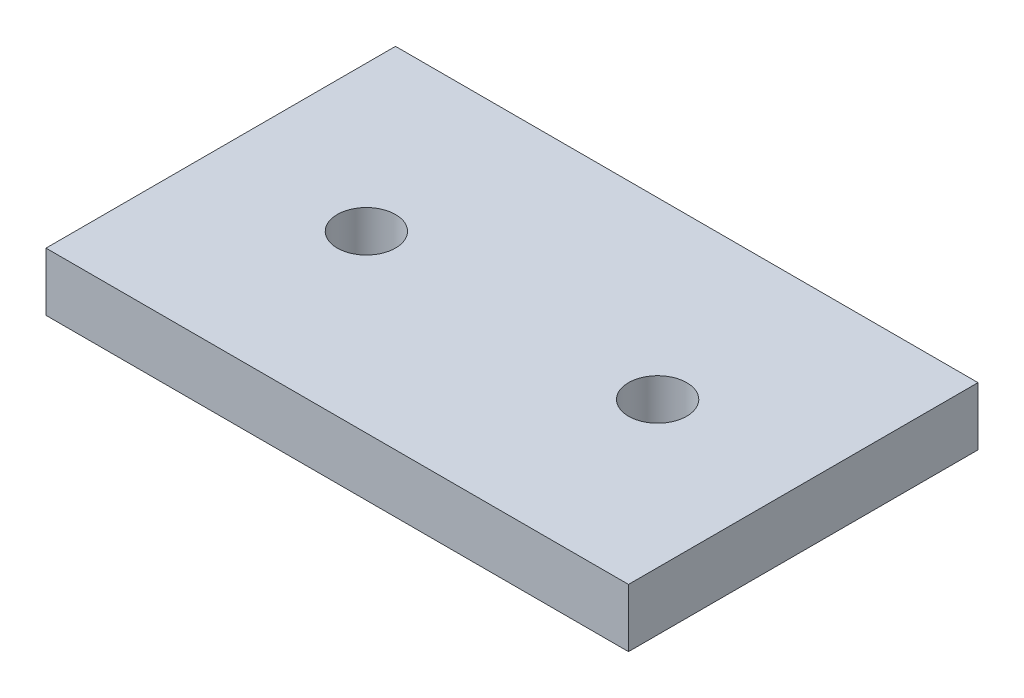
from build123d import *

# Parameters (mm, degrees)
SKETCH_1_W          = 100
SKETCH_1_H          = 60
EXTRUDE_1_DEPTH     = 10
SKETCH_2_R          = 5
CUT_EXTRUDE_1_DEPTH = 11


with BuildPart() as part:
    # Эскиз1 → Бобышка-Вытянуть1 (new body)
    with BuildSketch(Plane(origin=(0, 0, 0), x_dir=(1, 0, 0), z_dir=(0, 1, 0))):
        with Locations((50, 30)):
            Rectangle(SKETCH_1_W, SKETCH_1_H)
    extrude(amount=EXTRUDE_1_DEPTH)

    # Эскиз2 → Вырез-Вытянуть1 (cut, through all)
    with BuildSketch(Plane(origin=(0, 10, 0), x_dir=(1, 0, 0), z_dir=(0, 1, 0))):
        with Locations((25, 30)):
            Circle(SKETCH_2_R)
        with Locations((75, 30)):
            Circle(SKETCH_2_R)
    extrude(amount=-CUT_EXTRUDE_1_DEPTH, mode=Mode.SUBTRACT)


solid = part.part
